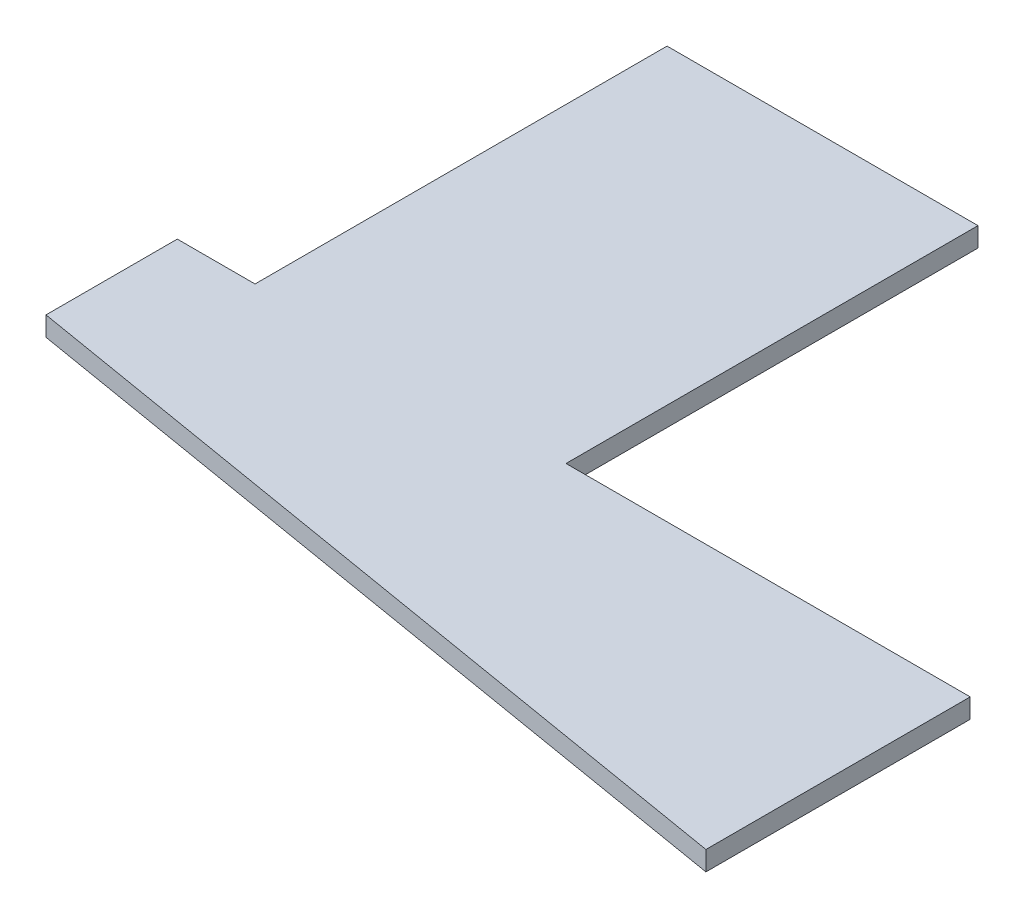
from build123d import *

# Parameters (mm, degrees)
BOSS_EXTRUDE1_DEPTH = 3.175


with BuildPart() as part:
    # Sketch2 → Boss-Extrude1 (new body)
    with BuildSketch(Plane(origin=(0, 0, 0), x_dir=(1, 0, 0), z_dir=(0, 1, 0))):
        Polygon((50.8, 0), (116.84, 0), (116.84, -43.18), (-12.7, -21.449244855), (-12.7, 0), (0, 0), (0, 67.31), (50.8, 67.31), align=None)
    extrude(amount=BOSS_EXTRUDE1_DEPTH)


solid = part.part
